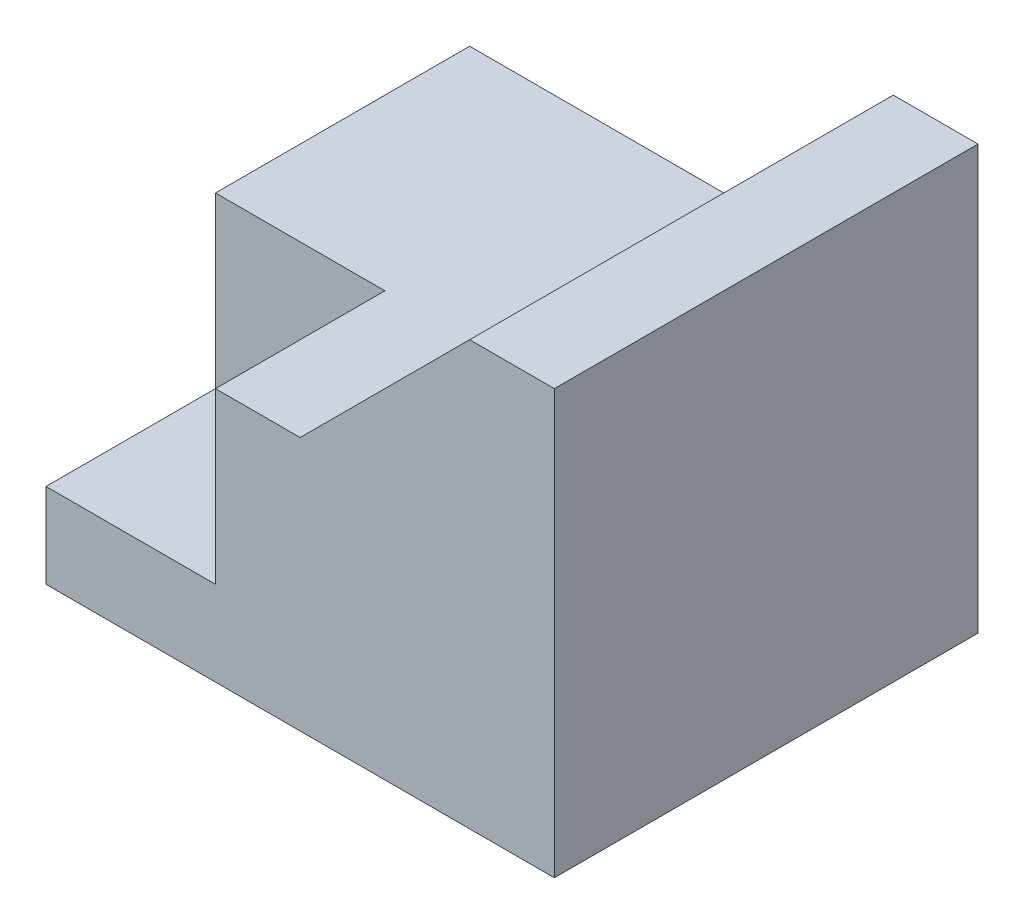
from build123d import *

# Parameters (mm, degrees)
BOSS_EXTRUDE2_DEPTH = 50
SKETCH3_W           = 20
SKETCH3_H           = 20
CUT_EXTRUDE2_DEPTH  = 20


with BuildPart() as part:
    # Sketch1 → Boss-Extrude2 (new body)
    with BuildSketch(Plane.XY):
        Polygon((0, 0), (0, 30), (30, 30), (50, 50), (60, 50), (60, 0), align=None)
    extrude(amount=BOSS_EXTRUDE2_DEPTH)

    # Sketch3 → Cut-Extrude2 (cut)
    with BuildSketch(Plane.XY.offset(50)):
        with Locations((10, 20)):
            Rectangle(SKETCH3_W, SKETCH3_H)
    extrude(amount=-CUT_EXTRUDE2_DEPTH, mode=Mode.SUBTRACT)


solid = part.part
